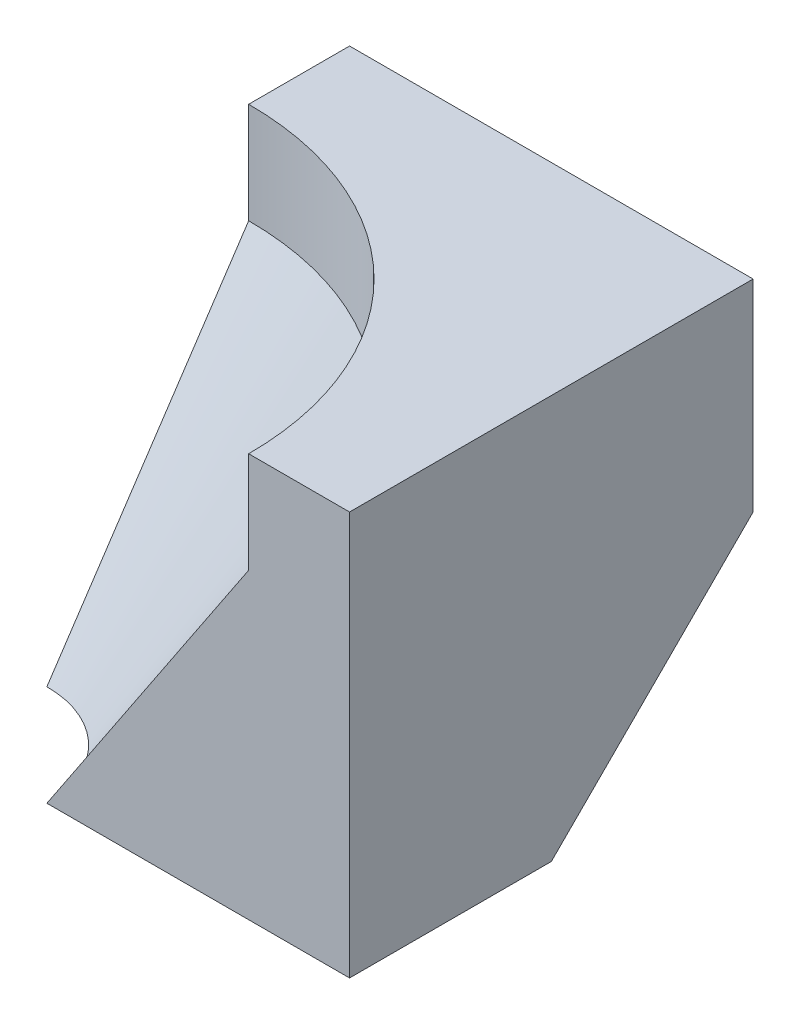
from build123d import *

# Parameters (mm, degrees)
SKETCH1_W           = 40
SKETCH1_H           = 40
BOSS_EXTRUDE1_DEPTH = 40
CUT_EXTRUDE1_DEPTH  = 40
CUT_EXTRUDE2_DEPTH  = 40
CUT_EXTRUDE3_DEPTH  = 10
BOSS_EXTRUDE2_DEPTH = 28
CUT_EXTRUDE11_DEPTH = 10
SKETCH20_W          = 40
SKETCH20_H          = 20
CUT_EXTRUDE12_DEPTH = 10
SKETCH21_W          = 40
SKETCH21_H          = 28.284271248
CUT_EXTRUDE13_DEPTH = 10
CUT_EXTRUDE14_DEPTH = 10
SKETCH23_W          = 40
SKETCH23_H          = 40
CUT_EXTRUDE15_DEPTH = 10
SKETCH24_W          = 40
SKETCH24_H          = 40
CUT_EXTRUDE16_DEPTH = 10
CUT_EXTRUDE17_DEPTH = 59
CUT_EXTRUDE18_DEPTH = 59


with BuildPart() as part:
    # Sketch1 → Boss-Extrude1 (new body)
    with BuildSketch(Plane.XY):
        with Locations((20, 20)):
            Rectangle(SKETCH1_W, SKETCH1_H)
    extrude(amount=BOSS_EXTRUDE1_DEPTH)

    # Sketch2 → Cut-Extrude1 (cut)
    with BuildSketch(Plane(origin=(0, 40, 0), x_dir=(1, 0, 0), z_dir=(0, 1, 0))):
        with BuildLine():
            Line((0, -30), (0, -40))
            Line((0, -40), (10, -40))
            ThreePointArc((10, -40), (7.071067812, -32.928932188), (0, -30))
        make_face()
    extrude(amount=-CUT_EXTRUDE1_DEPTH, mode=Mode.SUBTRACT)

    # Sketch3 → Cut-Extrude2 (cut)
    with BuildSketch(Plane(origin=(40, 0, 0), x_dir=(0, 0, -1), z_dir=(1, 0, 0))):
        Polygon((0, 20), (-20, 0), (0, 0), align=None)
    extrude(amount=-CUT_EXTRUDE2_DEPTH, mode=Mode.SUBTRACT)

    # Sketch4 → Cut-Extrude3 (cut)
    with BuildSketch(Plane(origin=(0, 40, 0), x_dir=(1, 0, 0), z_dir=(0, 1, 0))):
        with BuildLine():
            Line((0, -10), (0, -30))
            ThreePointArc((0, -30), (7.071067812, -32.928932188), (10, -40))
            Line((10, -40), (30, -40))
            ThreePointArc((30, -40), (21.213203436, -18.786796564), (0, -10))
        make_face()
    extrude(amount=-CUT_EXTRUDE3_DEPTH, mode=Mode.SUBTRACT)

    # Sketch8 → Boss-Extrude2 (add)
    with BuildSketch(Plane(origin=(-13.333333333, 6.666666667, 13.333333333), x_dir=(-0.745355992, -0.298142397, -0.596284794), z_dir=(0.666666667, -0.333333333, -0.666666667))):
        Polygon((-17.88854382, 31.304951685), (-17.88854382, -13.416407865), (-31.304951685, -17.88854382), (-58.137767415, 17.88854382), align=None)
    extrude(amount=BOSS_EXTRUDE2_DEPTH)

    # Sketch19 → Cut-Extrude11 (cut)
    with BuildSketch(Plane(origin=(0, 40, 0), x_dir=(1, 0, 0), z_dir=(0, 1, 0))):
        with BuildLine():
            Line((0, -10), (0, -40))
            Line((0, -40), (30, -40))
            ThreePointArc((30, -40), (21.213203436, -18.786796564), (0, -10))
        make_face()
    extrude(amount=-CUT_EXTRUDE11_DEPTH, mode=Mode.SUBTRACT)

    # Sketch20 → Cut-Extrude12 (cut)
    with BuildSketch(Plane(origin=(0, 0, 0), x_dir=(-1, 0, 0), z_dir=(0, 0, -1))):
        with Locations((-20, 30)):
            Rectangle(SKETCH20_W, SKETCH20_H)
    extrude(amount=CUT_EXTRUDE12_DEPTH, mode=Mode.SUBTRACT)

    # Sketch21 → Cut-Extrude13 (cut)
    with BuildSketch(Plane(origin=(0, 10, 10), x_dir=(1, 0, 0), z_dir=(0, -0.707106781, -0.707106781))):
        with Locations((20, 0)):
            Rectangle(SKETCH21_W, SKETCH21_H)
    extrude(amount=CUT_EXTRUDE13_DEPTH, mode=Mode.SUBTRACT)

    # Sketch22 → Cut-Extrude14 (cut)
    with BuildSketch(Plane(origin=(0, 10, -10), x_dir=(1, 0, 0), z_dir=(0, -0.707106781, 0.707106781))):
        Polygon((16, 14.142135624), (22, 14.142135624), (18.666666667, 10.999438818), align=None)
    extrude(amount=-CUT_EXTRUDE14_DEPTH, mode=Mode.SUBTRACT)

    # Sketch23 → Cut-Extrude15 (cut)
    with BuildSketch(Plane.XZ):
        with Locations((20, 20)):
            Rectangle(SKETCH23_W, SKETCH23_H)
    extrude(amount=CUT_EXTRUDE15_DEPTH, mode=Mode.SUBTRACT)

    # Sketch24 → Cut-Extrude16 (cut)
    with BuildSketch(Plane(origin=(40, 0, 0), x_dir=(0, 0, -1), z_dir=(1, 0, 0))):
        with Locations((-20, 20)):
            Rectangle(SKETCH24_W, SKETCH24_H)
    extrude(amount=CUT_EXTRUDE16_DEPTH, mode=Mode.SUBTRACT)

    # Sketch25 → Cut-Extrude17 (cut)
    with BuildSketch(Plane(origin=(-12.272727273, 8.181818182, 12.272727273), x_dir=(0.768706115, 0.354787438, 0.532181156), z_dir=(-0.639602149, 0.426401433, 0.639602149))):
        Polygon((15.965434692, -16.641005887), (15.965434692, 19.414506868), (54.992052827, 2.773500981), (28.974307403, -22.188007849), align=None)
    extrude(amount=CUT_EXTRUDE17_DEPTH, mode=Mode.SUBTRACT)

    # Sketch26 → Cut-Extrude18 (cut)
    with BuildSketch(Plane(origin=(0, 30, 0), x_dir=(1, 0, 0), z_dir=(0, 1, 0))):
        with BuildLine():
            Line((0, -30), (0, -40))
            Line((0, -40), (10, -40))
            ThreePointArc((10, -40), (7.071067812, -32.928932188), (0, -30))
        make_face()
    extrude(amount=-CUT_EXTRUDE18_DEPTH, mode=Mode.SUBTRACT)

    # Sketch27 → Cut-Revolve1 (revolve, cut)
    with BuildSketch(Plane.XY.offset(40)):
        Polygon((30, 30), (10, 0), (10, 30), align=None)
    revolve(axis=Axis((0, 0, 40), (0, 1, 0)), mode=Mode.SUBTRACT)


solid = part.part
